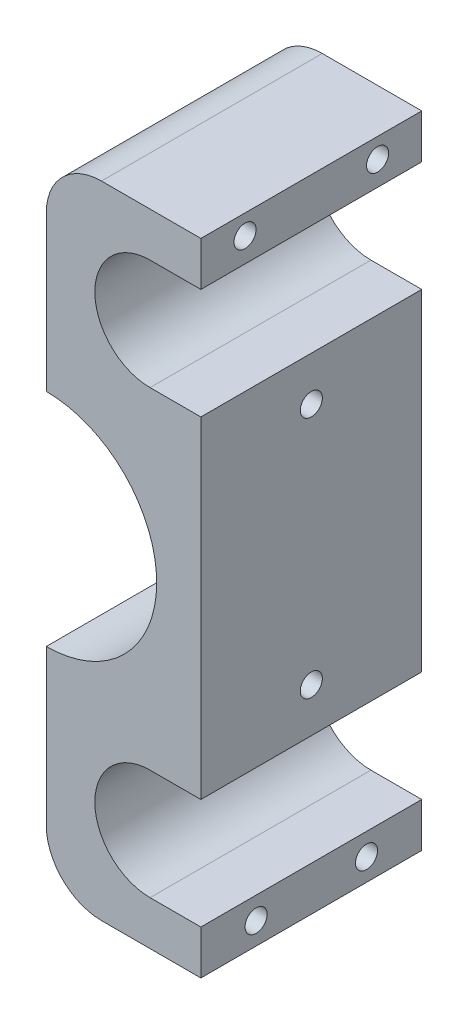
from build123d import *

# Parameters (mm, degrees)
EXTRUDE_1_DEPTH     = 20
FILLET_1_R          = 5
SKETCH_2_R          = 1
CUT_EXTRUDE_1_DEPTH = 10
SKETCH_3_R          = 10
CUT_EXTRUDE_2_DEPTH = 40


with BuildPart() as part:
    # 草图1 → 凸台-拉伸1 (new body)
    with BuildSketch(Plane.XY):
        with BuildLine():
            Line((0, 29), (0, 25))
            Line((0, 25), (-4.6, 25))
            ThreePointArc((-4.6, 25), (-9.6, 20), (-4.6, 15))
            Line((-4.6, 15), (0, 15))
            Line((0, 15), (0, -15))
            Line((0, -15), (-4.6, -15))
            ThreePointArc((-4.6, -15), (-9.6, -20), (-4.6, -25))
            Line((-4.6, -25), (0, -25))
            Line((0, -25), (0, -29))
            Line((0, -29), (-14, -29))
            Line((-14, -29), (-14, 29))
            Line((-14, 29), (0, 29))
        make_face()
    extrude(amount=EXTRUDE_1_DEPTH)

    # 圆角1
    fillet_1_edges = [part.edges().sort_by_distance(p)[0] for p in [
        (-14, -29, 10),
        (-14, 29, 10),
    ]]
    fillet(fillet_1_edges, radius=FILLET_1_R)

    # 草图2 → 切除-拉伸1 (cut)
    with BuildSketch(Plane(origin=(0, 0, 0), x_dir=(0, 0, -1), z_dir=(1, 0, 0))):
        with Locations((-16, 27.2)):
            Circle(SKETCH_2_R)
        with Locations((-4, 27.2)):
            Circle(SKETCH_2_R)
        with Locations((-10, 11)):
            Circle(SKETCH_2_R)
        with Locations((-10, -11)):
            Circle(SKETCH_2_R)
        with Locations((-15, -27)):
            Circle(SKETCH_2_R)
        with Locations((-5, -27)):
            Circle(SKETCH_2_R)
    extrude(amount=-CUT_EXTRUDE_1_DEPTH, mode=Mode.SUBTRACT)

    # 草图3 → 切除-拉伸2 (cut)
    with BuildSketch(Plane.XY.offset(20)):
        with Locations((-14, 0)):
            Circle(SKETCH_3_R)
    extrude(amount=-CUT_EXTRUDE_2_DEPTH, mode=Mode.SUBTRACT)


solid = part.part
